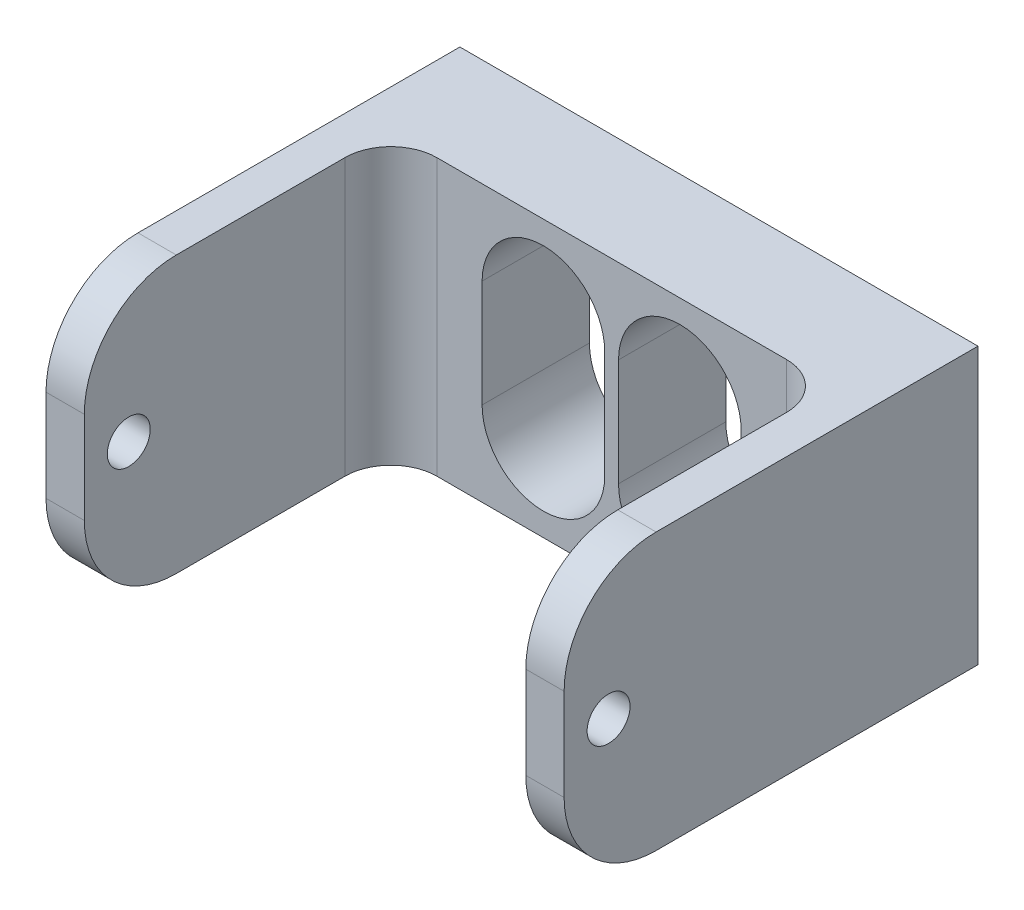
from build123d import *

# Parameters (mm, degrees)
SKETCH1_W           = 33.8
SKETCH1_H           = 18
BOSS_EXTRUDE1_DEPTH = 7
SKETCH2_W           = 2.5
SKETCH2_H           = 18
BOSS_EXTRUDE2_DEPTH = 20
SKETCH3_R           = 1.4
CUT_EXTRUDE1_DEPTH  = 34.8
FILLET1_R           = 6
FILLET2_R           = 3


with BuildPart() as part:
    # Sketch1 → Boss-Extrude1 (new body)
    with BuildSketch(Plane.XY):
        Rectangle(SKETCH1_W, SKETCH1_H)
        with BuildLine():
            Line((-0.45, 3.5), (-0.45, -3.5))
            ThreePointArc((-0.45, -3.5), (-4.45, -7.5), (-8.45, -3.5))
            Line((-8.45, -3.5), (-8.45, 3.5))
            ThreePointArc((-8.45, 3.5), (-4.45, 7.5), (-0.45, 3.5))
        make_face(mode=Mode.SUBTRACT)
        with BuildLine():
            Line((8.45, 3.5), (8.45, -3.5))
            ThreePointArc((8.45, -3.5), (4.45, -7.5), (0.45, -3.5))
            Line((0.45, -3.5), (0.45, 3.5))
            ThreePointArc((0.45, 3.5), (4.45, 7.5), (8.45, 3.5))
        make_face(mode=Mode.SUBTRACT)
    extrude(amount=BOSS_EXTRUDE1_DEPTH)

    # Sketch2 → Boss-Extrude2 (add)
    with BuildSketch(Plane.XY.offset(7)):
        with Locations((-15.65, 0)):
            Rectangle(SKETCH2_W, SKETCH2_H)
        with Locations((15.65, 0)):
            Rectangle(SKETCH2_W, SKETCH2_H)
    extrude(amount=BOSS_EXTRUDE2_DEPTH)

    # Sketch3 → Cut-Extrude1 (cut, through all)
    with BuildSketch(Plane(origin=(16.9, 0, 0), x_dir=(0, 0, -1), z_dir=(1, 0, 0))):
        with Locations((-24.1, 0)):
            Circle(SKETCH3_R)
    extrude(amount=-CUT_EXTRUDE1_DEPTH, mode=Mode.SUBTRACT)

    # Fillet1
    fillet1_edges = [part.edges().sort_by_distance(p)[0] for p in [
        (15.65, -9, 27),
        (-15.65, -9, 27),
        (-15.65, 9, 27),
        (15.65, 9, 27),
    ]]
    fillet(fillet1_edges, radius=FILLET1_R)

    # Fillet2
    fillet2_edges = [part.edges().sort_by_distance(p)[0] for p in [
        (14.4, 0, 7),
        (-14.4, 0, 7),
    ]]
    fillet(fillet2_edges, radius=FILLET2_R)


solid = part.part
